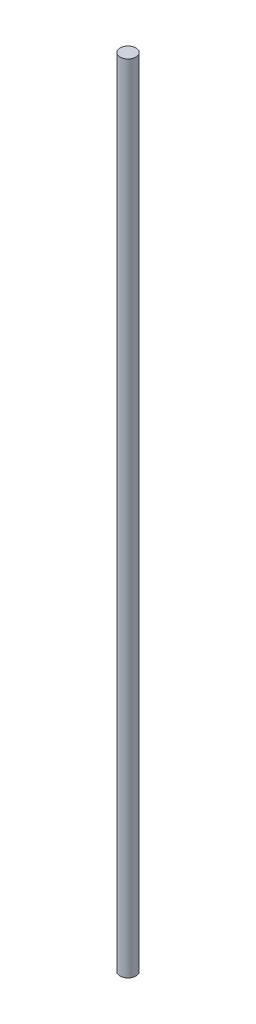
from build123d import *

# Parameters (mm, degrees)
SKETCH1_R           = 5
BOSS_EXTRUDE1_DEPTH = 500


with BuildPart() as part:
    # Sketch1 → Boss-Extrude1 (new body)
    with BuildSketch(Plane(origin=(0, 0, 0), x_dir=(1, 0, 0), z_dir=(0, 1, 0))):
        Circle(SKETCH1_R)
    extrude(amount=BOSS_EXTRUDE1_DEPTH)


solid = part.part
